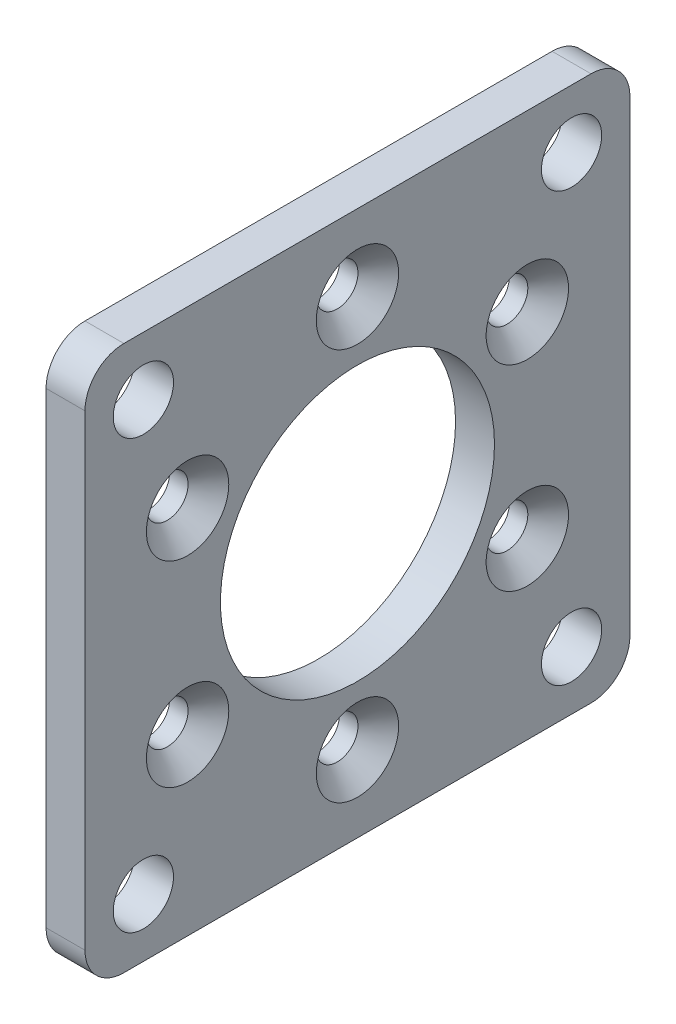
from build123d import *

# Parameters (mm, degrees)
SKETCH1_W                        = 44.45
SKETCH1_H                        = 44.45
SKETCH1_R                        = 11.176
BOSS_EXTRUDE1_DEPTH              = 3.175
F_10_0_1935_DIAMETER_HOLE1_D     = 4.9149
F_10_0_1935_DIAMETER_HOLE1_DEPTH = 3.175
CSK_FOR_M3_SFHCS1_AT_2_COUNT     = 2
CSK_FOR_M3_SFHCS1_AT_2_PITCH     = 16
CSK_FOR_M3_SFHCS1_AT_3_COUNT     = 2
CSK_FOR_M3_SFHCS1_AT_3_PITCH     = 27.712812921
CSK_FOR_M3_SFHCS1_AT_4_COUNT     = 2
CSK_FOR_M3_SFHCS1_AT_4_PITCH     = 32
CSK_FOR_M3_SFHCS1_AT_5_COUNT     = 2
CSK_FOR_M3_SFHCS1_AT_5_PITCH     = 27.712812921
CSK_FOR_M3_SFHCS1_AT_6_COUNT     = 2
CSK_FOR_M3_SFHCS1_AT_6_PITCH     = 16
FILLET1_R                        = 3.175


with BuildPart() as part:
    # Sketch1 → Boss-Extrude1 (new body)
    with BuildSketch(Plane(origin=(0, 0, 0), x_dir=(0, 0, -1), z_dir=(1, 0, 0))):
        Rectangle(SKETCH1_W, SKETCH1_H)
        Circle(SKETCH1_R, mode=Mode.SUBTRACT)
    extrude(amount=BOSS_EXTRUDE1_DEPTH)

    # #10 (0.1935) Diameter Hole1
    with Locations(Plane(origin=(3.175, 0, 0), x_dir=(0, 0, -1), z_dir=(1, 0, 0))):
        with Locations((-17.4625, 17.4625), (17.4625, 17.4625), (17.4625, -17.4625), (-17.4625, -17.4625)):
            Hole(F_10_0_1935_DIAMETER_HOLE1_D / 2, depth=F_10_0_1935_DIAMETER_HOLE1_DEPTH)

    # Sketch6 → CSK for M3 SFHCS1 (revolve, cut)
    with BuildSketch(Plane(origin=(3.175, 8, 13.856406461), x_dir=(0, 0, -1), z_dir=(0, 1, 0))):
        Polygon((0, 0), (0, 3.175), (1.7, 3.175), (1.7, 1.66), (3.36, 0), align=None)
    csk_for_m3_sfhcs1 = revolve(axis=Axis((9.525, 8, 13.856406461), (-1, 0, 0)), mode=Mode.SUBTRACT)

    # CSK for M3 SFHCS1 at 2: CSK for M3 SFHCS1 ×2
    with Locations(*[Vector(0, 0.5, -0.866025404) * (i * CSK_FOR_M3_SFHCS1_AT_2_PITCH) for i in range(1, CSK_FOR_M3_SFHCS1_AT_2_COUNT)]):
        add(csk_for_m3_sfhcs1, mode=Mode.SUBTRACT)

    # CSK for M3 SFHCS1 at 3: CSK for M3 SFHCS1 ×2
    with Locations(*[(0, 0, -i * CSK_FOR_M3_SFHCS1_AT_3_PITCH) for i in range(1, CSK_FOR_M3_SFHCS1_AT_3_COUNT)]):
        add(csk_for_m3_sfhcs1, mode=Mode.SUBTRACT)

    # CSK for M3 SFHCS1 at 4: CSK for M3 SFHCS1 ×2
    with Locations(*[Vector(0, -0.5, -0.866025404) * (i * CSK_FOR_M3_SFHCS1_AT_4_PITCH) for i in range(1, CSK_FOR_M3_SFHCS1_AT_4_COUNT)]):
        add(csk_for_m3_sfhcs1, mode=Mode.SUBTRACT)

    # CSK for M3 SFHCS1 at 5: CSK for M3 SFHCS1 ×2
    with Locations(*[Vector(0, -0.866025404, -0.5) * (i * CSK_FOR_M3_SFHCS1_AT_5_PITCH) for i in range(1, CSK_FOR_M3_SFHCS1_AT_5_COUNT)]):
        add(csk_for_m3_sfhcs1, mode=Mode.SUBTRACT)

    # CSK for M3 SFHCS1 at 6: CSK for M3 SFHCS1 ×2
    with Locations(*[(0, -i * CSK_FOR_M3_SFHCS1_AT_6_PITCH, 0) for i in range(1, CSK_FOR_M3_SFHCS1_AT_6_COUNT)]):
        add(csk_for_m3_sfhcs1, mode=Mode.SUBTRACT)

    # Fillet1
    fillet1_edges = [part.edges().sort_by_distance(p)[0] for p in [
        (1.5875, 22.225, 22.225),
        (1.5875, 22.225, -22.225),
        (1.5875, -22.225, -22.225),
        (1.5875, -22.225, 22.225),
    ]]
    fillet(fillet1_edges, radius=FILLET1_R)


solid = part.part
